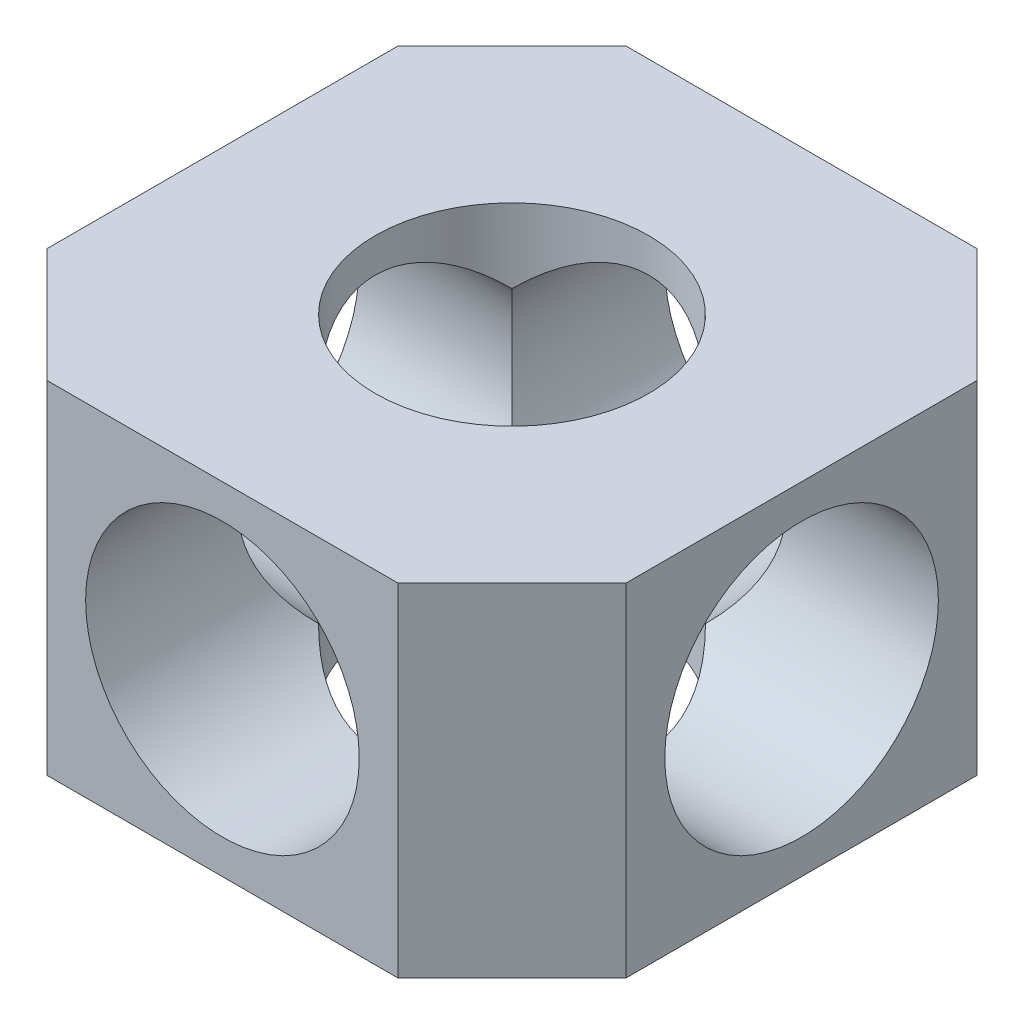
from build123d import *

# Parameters (mm, degrees)
IZIM2_R                     = 6
Y_KSEKLIK_EKSTR_ZYON1_DEPTH = 7.5
IZIM3_R                     = 6
KES_EKSTR_ZYON1_DEPTH       = 26.4
IZIM4_R                     = 6
KES_EKSTR_ZYON2_DEPTH       = 26.4


with BuildPart() as part:
    # Çizim2 → Yükseklik-Ekstrüzyon1 (new body, symmetric)
    with BuildSketch(Plane(origin=(0, 0, 0), x_dir=(1, 0, 0), z_dir=(0, 1, 0))):
        Polygon((-12.7, -7.7), (-7.7, -12.7), (7.7, -12.7), (12.7, -7.7), (12.7, 7.7), (7.7, 12.7), (-7.7, 12.7), (-12.7, 7.7), align=None)
        Circle(IZIM2_R, mode=Mode.SUBTRACT)
    extrude(amount=Y_KSEKLIK_EKSTR_ZYON1_DEPTH, both=True)

    # Çizim3 → Kes-Ekstrüzyon1 (cut, through all)
    with BuildSketch(Plane.XY.offset(12.7)):
        Circle(IZIM3_R)
    extrude(amount=-KES_EKSTR_ZYON1_DEPTH, mode=Mode.SUBTRACT)

    # Çizim4 → Kes-Ekstrüzyon2 (cut, through all)
    with BuildSketch(Plane(origin=(12.7, 0, 0), x_dir=(0, 0, -1), z_dir=(1, 0, 0))):
        Circle(IZIM4_R)
    extrude(amount=-KES_EKSTR_ZYON2_DEPTH, mode=Mode.SUBTRACT)


solid = part.part
